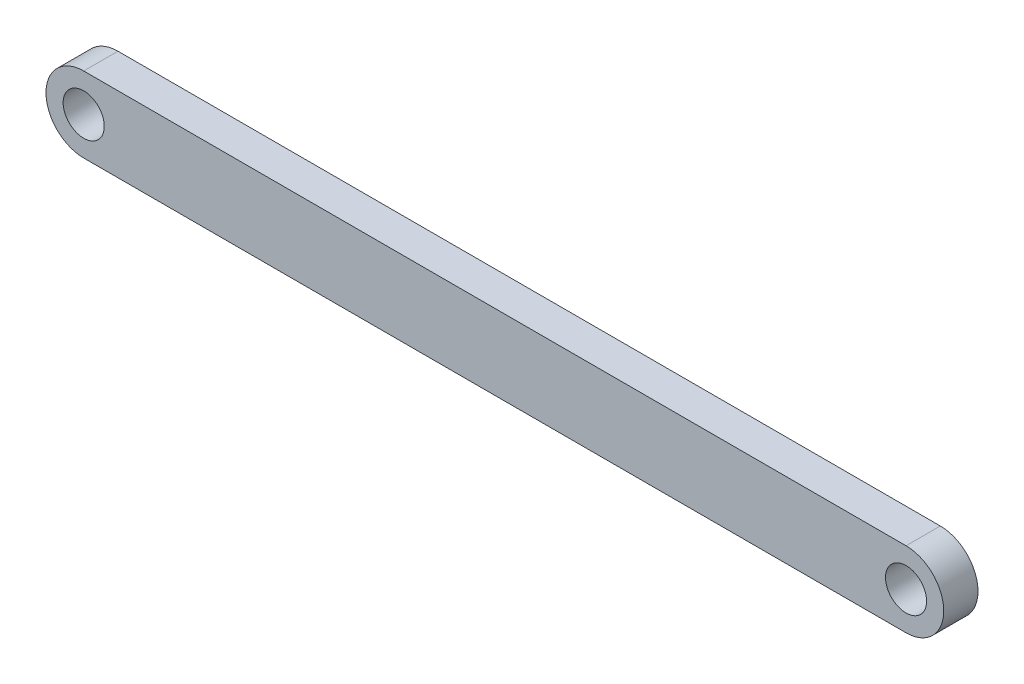
from build123d import *

# Parameters (mm, degrees)
SKETCH1_R           = 3
BOSS_EXTRUDE1_DEPTH = 2.5


with BuildPart() as part:
    # Sketch1 → Boss-Extrude1 (new body, symmetric)
    with BuildSketch(Plane.XY):
        with BuildLine():
            Line((-60, 5.5), (60, 5.5))
            ThreePointArc((60, 5.5), (65.5, 0), (60, -5.5))
            Line((60, -5.5), (-60, -5.5))
            ThreePointArc((-60, -5.5), (-65.5, 0), (-60, 5.5))
        make_face()
        with Locations((-60, 0)):
            Circle(SKETCH1_R, mode=Mode.SUBTRACT)
        with Locations((60, 0)):
            Circle(SKETCH1_R, mode=Mode.SUBTRACT)
    extrude(amount=BOSS_EXTRUDE1_DEPTH, both=True)


solid = part.part
